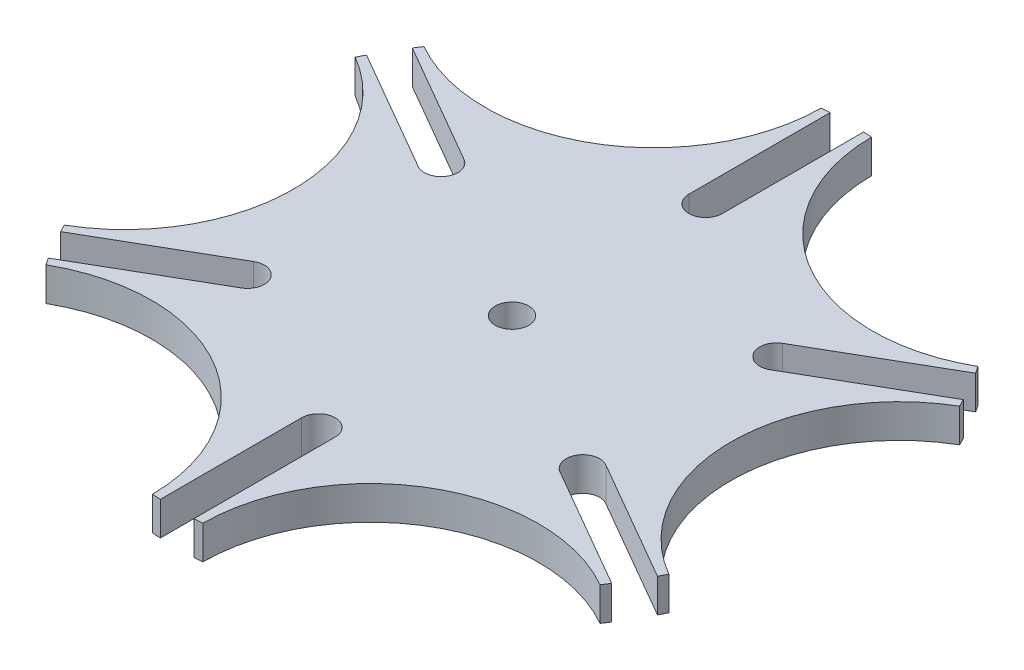
from build123d import *

# Parameters (mm, degrees)
SKETCH1_R           = 5
BOSS_EXTRUDE1_DEPTH = 10


with BuildPart() as part:
    # Sketch1 → Boss-Extrude1 (new body)
    with BuildSketch(Plane(origin=(0, 0, 0), x_dir=(1, 0, 0), z_dir=(0, 1, 0))):
        with BuildLine():
            ThreePointArc((7.500789876, 99.718293965), (6.250885533, 99.804440934), (5, 99.874921777))
            Line((5, 99.874921777), (5, 57.735026919))
            ThreePointArc((5, 57.735026919), (0, 52.735026919), (-5, 57.735026919))
            Line((-5, 57.735026919), (-5, 99.874921777))
            ThreePointArc((-5, 99.874921777), (-6.250885533, 99.804440934), (-7.500789876, 99.718293965))
            ThreePointArc((-7.500789876, 99.718293965), (-32.617513459, 56.495190528), (-82.608180857, 56.355021564))
            ThreePointArc((-82.608180857, 56.355021564), (-83.307738492, 55.315646135), (-83.99421946, 54.267587908))
            Line((-83.99421946, 54.267587908), (-47.5, 33.197640478))
            ThreePointArc((-47.5, 33.197640478), (-45.669872981, 26.367513459), (-52.5, 24.537386441))
            Line((-52.5, 24.537386441), (-88.99421946, 45.60733387))
            ThreePointArc((-88.99421946, 45.60733387), (-89.558624026, 44.488794799), (-90.108970734, 43.363272401))
            ThreePointArc((-90.108970734, 43.363272401), (-65.235026919, 0), (-90.108970734, -43.363272401))
            ThreePointArc((-90.108970734, -43.363272401), (-89.558624026, -44.488794799), (-88.99421946, -45.60733387))
            Line((-88.99421946, -45.60733387), (-52.5, -24.537386441))
            ThreePointArc((-52.5, -24.537386441), (-45.669872981, -26.367513459), (-47.5, -33.197640478))
            Line((-47.5, -33.197640478), (-83.99421946, -54.267587908))
            ThreePointArc((-83.99421946, -54.267587908), (-83.307738492, -55.315646135), (-82.608180857, -56.355021564))
            ThreePointArc((-82.608180857, -56.355021564), (-32.617513459, -56.495190528), (-7.500789876, -99.718293965))
            ThreePointArc((-7.500789876, -99.718293965), (-6.250885533, -99.804440934), (-5, -99.874921777))
            Line((-5, -99.874921777), (-5, -57.735026919))
            ThreePointArc((-5, -57.735026919), (0, -52.735026919), (5, -57.735026919))
            Line((5, -57.735026919), (5, -99.874921777))
            ThreePointArc((5, -99.874921777), (6.250885533, -99.804440934), (7.500789876, -99.718293965))
            ThreePointArc((7.500789876, -99.718293965), (32.617513459, -56.495190528), (82.608180857, -56.355021564))
            ThreePointArc((82.608180857, -56.355021564), (83.307738492, -55.315646135), (83.99421946, -54.267587908))
            Line((83.99421946, -54.267587908), (47.5, -33.197640478))
            ThreePointArc((47.5, -33.197640478), (45.669872981, -26.367513459), (52.5, -24.537386441))
            Line((52.5, -24.537386441), (88.99421946, -45.60733387))
            ThreePointArc((88.99421946, -45.60733387), (89.558624026, -44.488794799), (90.108970734, -43.363272401))
            ThreePointArc((90.108970734, -43.363272401), (65.235026919, 0), (90.108970734, 43.363272401))
            ThreePointArc((90.108970734, 43.363272401), (89.558624026, 44.488794799), (88.99421946, 45.60733387))
            Line((88.99421946, 45.60733387), (52.5, 24.537386441))
            ThreePointArc((52.5, 24.537386441), (45.669872981, 26.367513459), (47.5, 33.197640478))
            Line((47.5, 33.197640478), (83.99421946, 54.267587908))
            ThreePointArc((83.99421946, 54.267587908), (83.307738492, 55.315646135), (82.608180857, 56.355021564))
            ThreePointArc((82.608180857, 56.355021564), (32.617513459, 56.495190528), (7.500789876, 99.718293965))
        make_face()
        with Locations(Location((0, 0, 0), (0, 0, 270))):  # turned: the seam where the file's is
            Circle(SKETCH1_R, mode=Mode.SUBTRACT)
    extrude(amount=BOSS_EXTRUDE1_DEPTH)


solid = part.part
